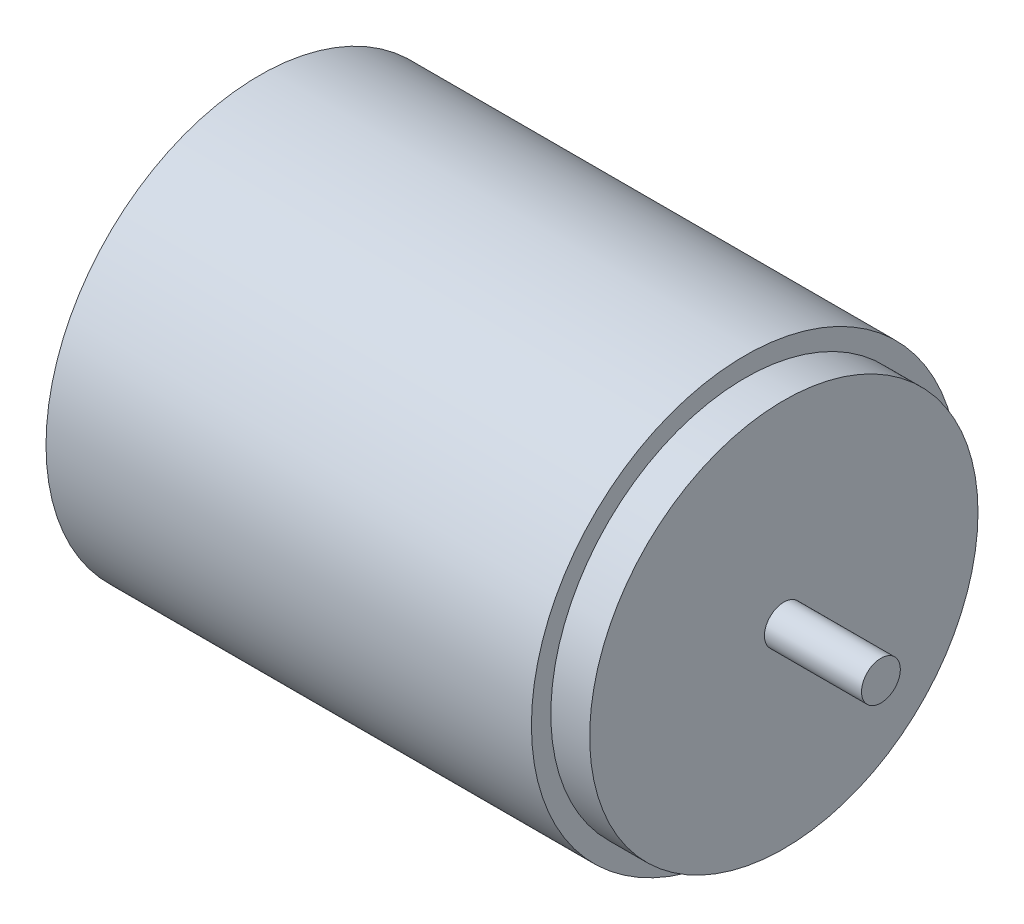
from build123d import *

# Parameters (mm, degrees)
SKETCH1_R           = 11
BOSS_EXTRUDE1_DEPTH = 25
SKETCH2_R           = 10
BOSS_EXTRUDE2_DEPTH = 2
SKETCH3_R           = 1
BOSS_EXTRUDE3_DEPTH = 5


with BuildPart() as part:
    # Sketch1 → Boss-Extrude1 (new body)
    with BuildSketch(Plane(origin=(0, 0, 0), x_dir=(0, 0, -1), z_dir=(1, 0, 0))):
        Circle(SKETCH1_R)
    extrude(amount=BOSS_EXTRUDE1_DEPTH)

    # Sketch2 → Boss-Extrude2 (add)
    with BuildSketch(Plane(origin=(25, 0, 0), x_dir=(0, 0, -1), z_dir=(1, 0, 0))):
        Circle(SKETCH2_R)
    extrude(amount=BOSS_EXTRUDE2_DEPTH)

    # Sketch3 → Boss-Extrude3 (add)
    with BuildSketch(Plane(origin=(27, 0, 0), x_dir=(0, 0, -1), z_dir=(1, 0, 0))):
        Circle(SKETCH3_R)
    extrude(amount=BOSS_EXTRUDE3_DEPTH)


solid = part.part
